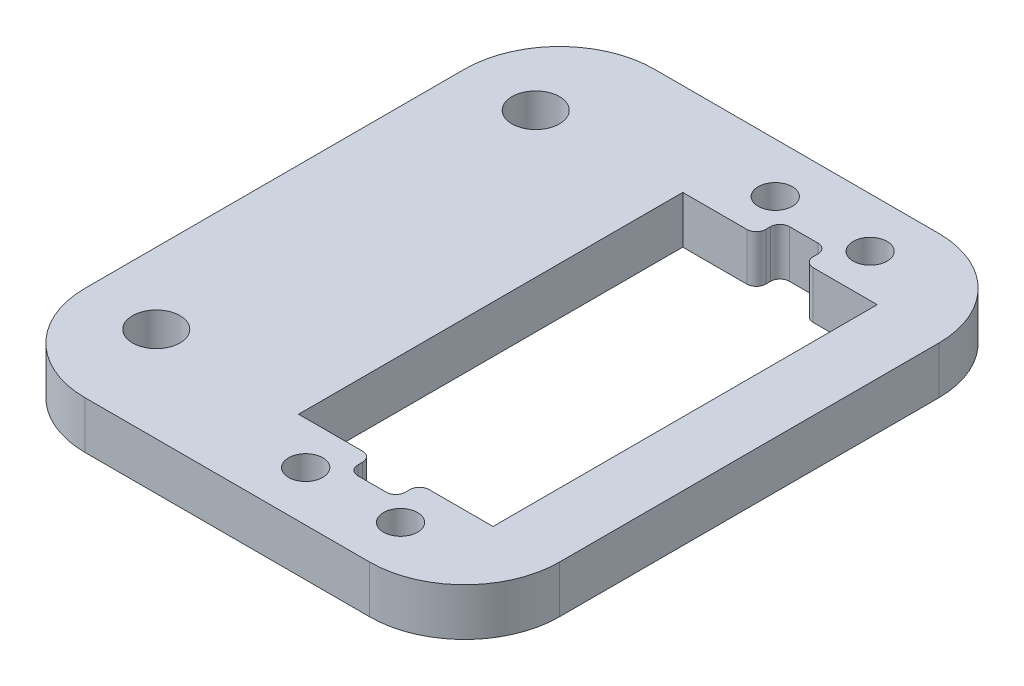
from build123d import *

# Parameters (mm, degrees)
SKETCH1_W           = 50
SKETCH1_H           = 60
BOSS_EXTRUDE1_DEPTH = 5
SKETCH2_W           = 20.5
SKETCH2_H           = 40.5
CUT_EXTRUDE1_DEPTH  = 5
SKETCH3_R           = 1.8
CUT_EXTRUDE2_DEPTH  = 5
SKETCH4_R           = 2.5
CUT_EXTRUDE3_DEPTH  = 5
FILLET1_R           = 10
SKETCH5_W           = 5
SKETCH5_H           = 5
CUT_EXTRUDE4_DEPTH  = 10
FILLET2_R           = 1


with BuildPart() as part:
    # Sketch1 → Boss-Extrude1 (new body)
    with BuildSketch(Plane(origin=(0, 0, 0), x_dir=(1, 0, 0), z_dir=(0, 1, 0))):
        Rectangle(SKETCH1_W, SKETCH1_H)
    extrude(amount=BOSS_EXTRUDE1_DEPTH)

    # Sketch2 → Cut-Extrude1 (cut)
    with BuildSketch(Plane(origin=(0, 5, 0), x_dir=(1, 0, 0), z_dir=(0, 1, 0))):
        with Locations((8, 0)):
            Rectangle(SKETCH2_W, SKETCH2_H)
    extrude(amount=-CUT_EXTRUDE1_DEPTH, mode=Mode.SUBTRACT)

    # Sketch3 → Cut-Extrude2 (cut)
    with BuildSketch(Plane(origin=(0, 5, 0), x_dir=(1, 0, 0), z_dir=(0, 1, 0))):
        with Locations((3, 24.75)):
            Circle(SKETCH3_R)
        with Locations((13, 24.75)):
            Circle(SKETCH3_R)
        with Locations((13, -24.75)):
            Circle(SKETCH3_R)
        with Locations((3, -24.75)):
            Circle(SKETCH3_R)
    extrude(amount=-CUT_EXTRUDE2_DEPTH, mode=Mode.SUBTRACT)

    # Sketch4 → Cut-Extrude3 (cut)
    with BuildSketch(Plane(origin=(0, 5, 0), x_dir=(1, 0, 0), z_dir=(0, 1, 0))):
        with Locations((-17.5, 20)):
            Circle(SKETCH4_R)
        with Locations((-17.5, -20)):
            Circle(SKETCH4_R)
    extrude(amount=-CUT_EXTRUDE3_DEPTH, mode=Mode.SUBTRACT)

    # Fillet1
    fillet1_edges = [part.edges().sort_by_distance(p)[0] for p in [
        (-25, 2.5, -30),
        (25, 2.5, -30),
        (25, 2.5, 30),
        (-25, 2.5, 30),
    ]]
    fillet(fillet1_edges, radius=FILLET1_R)

    # Sketch5 → Cut-Extrude4 (cut)
    with BuildSketch(Plane(origin=(0, 5, 0), x_dir=(1, 0, 0), z_dir=(0, 1, 0))):
        with Locations((8, 20.25)):
            Rectangle(SKETCH5_W, SKETCH5_H)
    cut_extrude4 = extrude(amount=-CUT_EXTRUDE4_DEPTH, mode=Mode.SUBTRACT)

    # Mirror1: Cut-Extrude4 across plane
    add(cut_extrude4.mirror(Plane.XY), mode=Mode.SUBTRACT)

    # Fillet2
    fillet2_edges = [part.edges().sort_by_distance(p)[0] for p in [
        (10.5, 2.5, 20.25),
        (5.5, 2.5, 20.25),
        (10.5, 2.5, 22.75),
        (5.5, 2.5, 22.75),
        (10.5, 2.5, -20.25),
        (5.5, 2.5, -20.25),
        (5.5, 2.5, -22.75),
        (10.5, 2.5, -22.75),
    ]]
    fillet(fillet2_edges, radius=FILLET2_R)


solid = part.part
